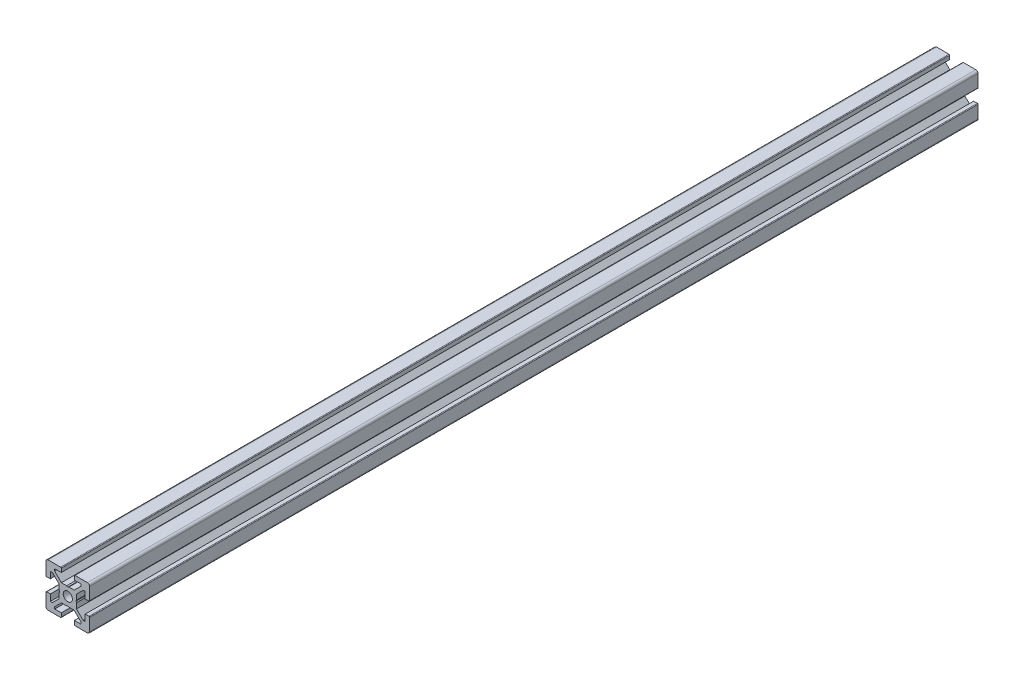
from build123d import *

# Parameters (mm, degrees)
BOSS_EXTRUDE1_DEPTH = 407.5
SKETCH2_W           = 407.5
SKETCH2_H           = 2.1


with BuildPart() as part:
    # Sketch1 → Boss-Extrude1 (new body)
    with BuildSketch(Plane.XY):
        with BuildLine():
            Line((-10, 9), (-10, 3.29999995))
            ThreePointArc((-10, 3.29999995), (-9.912132049, 3.087867916), (-9.7, 3))
            Line((-9.7, 3), (-8, 3))
            Line((-8, 3), (-8, 6))
            Line((-8, 6), (-7.060677, 6))
            Line((-7.060677, 6), (-4, 2.93932965))
            Line((-4, 2.93932965), (-4, 0.519615242))
            Line((-4, 0.519615242), (-3.699996283, -6.437e-06))
            Line((-3.699996283, -6.437e-06), (-4, -0.519628117))
            Line((-4, -0.519628117), (-4, -2.93933725))
            Line((-4, -2.93933725), (-7.0606695, -6))
            Line((-7.0606695, -6), (-8, -6))
            Line((-8, -6), (-8, -3))
            Line((-8, -3), (-9.7, -3))
            ThreePointArc((-9.7, -3), (-9.912132049, -3.087867916), (-10, -3.29999995))
            Line((-10, -3.29999995), (-10, -9))
            ThreePointArc((-10, -9), (-9.707106781, -9.707106781), (-9, -10))
            Line((-9, -10), (-3.29999995, -10))
            ThreePointArc((-3.29999995, -10), (-3.087867916, -9.912132049), (-3, -9.7))
            Line((-3, -9.7), (-3, -8))
            Line((-3, -8), (-6, -8))
            Line((-6, -8), (-6, -7.0606515))
            Line((-6, -7.0606515), (-2.9393489, -4))
            Line((-2.9393489, -4), (-0.519615242, -4))
            Line((-0.519615242, -4), (6.437e-06, -3.699996283))
            Line((6.437e-06, -3.699996283), (0.519628117, -4))
            Line((0.519628117, -4), (2.9393227, -4))
            Line((2.9393227, -4), (6, -7.060677))
            Line((6, -7.060677), (6, -8))
            Line((6, -8), (3, -8))
            Line((3, -8), (3, -9.7))
            ThreePointArc((3, -9.7), (3.087867916, -9.912132049), (3.29999995, -10))
            Line((3.29999995, -10), (9, -10))
            ThreePointArc((9, -10), (9.707106781, -9.707106781), (10, -9))
            Line((10, -9), (10, -3.29999995))
            ThreePointArc((10, -3.29999995), (9.912132049, -3.087867916), (9.7, -3))
            Line((9.7, -3), (8, -3))
            Line((8, -3), (8, -6))
            Line((8, -6), (7.0606435, -6))
            Line((7.0606435, -6), (4, -2.9393482))
            Line((4, -2.9393482), (4, -0.519615242))
            Line((4, -0.519615242), (3.699996283, 6.437e-06))
            Line((3.699996283, 6.437e-06), (4, 0.519628117))
            Line((4, 0.519628117), (4, 2.9393401))
            Line((4, 2.9393401), (7.060651, 6))
            Line((7.060651, 6), (8, 6))
            Line((8, 6), (8, 3))
            Line((8, 3), (9.7, 3))
            ThreePointArc((9.7, 3), (9.912132049, 3.087867916), (10, 3.29999995))
            Line((10, 3.29999995), (10, 9))
            ThreePointArc((10, 9), (9.707106781, 9.707106781), (9, 10))
            Line((9, 10), (3.29999995, 10))
            ThreePointArc((3.29999995, 10), (3.087867916, 9.912132049), (3, 9.7))
            Line((3, 9.7), (3, 8))
            Line((3, 8), (6, 8))
            Line((6, 8), (6, 7.060669))
            Line((6, 7.060669), (2.9393308, 4))
            Line((2.9393308, 4), (0.519615242, 4))
            Line((0.519615242, 4), (-6.437e-06, 3.699996283))
            Line((-6.437e-06, 3.699996283), (-0.519628117, 4))
            Line((-0.519628117, 4), (-2.93935655, 4))
            Line((-2.93935655, 4), (-6, 7.0606435))
            Line((-6, 7.0606435), (-6, 8))
            Line((-6, 8), (-3, 8))
            Line((-3, 8), (-3, 9.7))
            ThreePointArc((-3, 9.7), (-3.087867966, 9.912132034), (-3.3, 10))
            Line((-3.3, 10), (-9, 10))
            ThreePointArc((-9, 10), (-9.707106781, 9.707106781), (-10, 9))
        make_face()
    extrude(amount=-BOSS_EXTRUDE1_DEPTH)

    # Sketch2 → Cut-Revolve1 (revolve, cut)
    with BuildSketch(Plane(origin=(0, 0, 0), x_dir=(0, 0, -1), z_dir=(1, 0, 0))):
        with Locations((203.75, 1.05)):
            Rectangle(SKETCH2_W, SKETCH2_H)
    revolve(axis=Axis((0, 0, -407.5), (0, 0, 1)), mode=Mode.SUBTRACT)


solid = part.part
